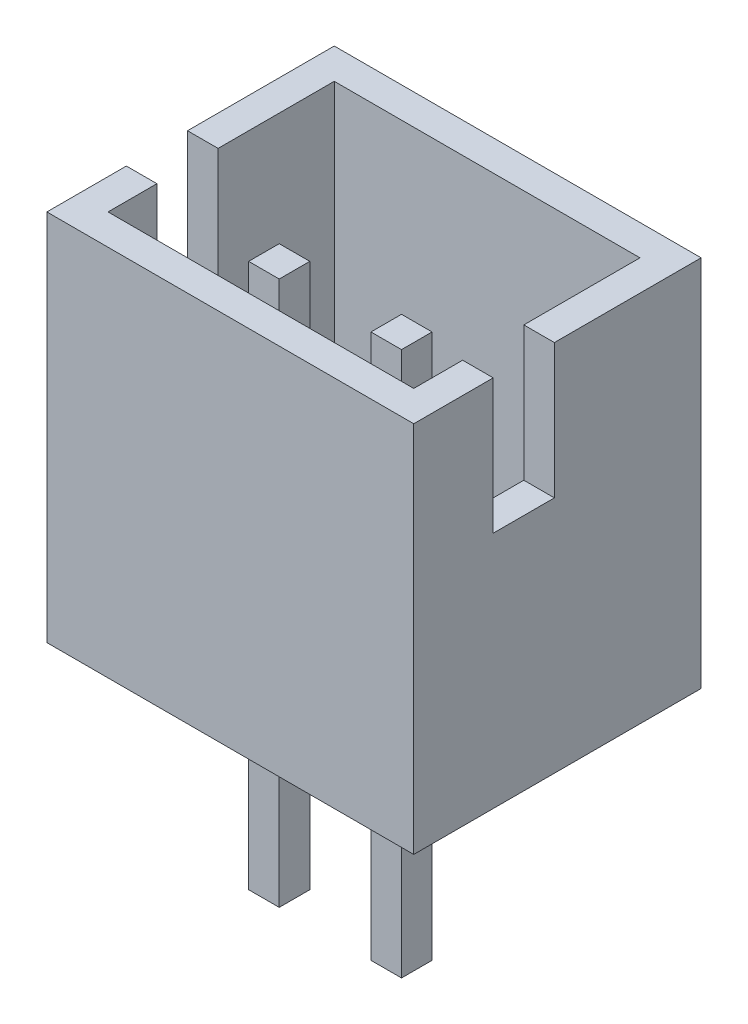
from build123d import *

# Parameters (mm, degrees)
SKETCH1_W                  = 6
SKETCH1_H                  = 4.7
BOSS_EXTRUDE1_DEPTH        = 6.1
SHELL1_T                   = -0.5
SKETCH2_W                  = 0.5
SKETCH2_H                  = 0.5
BOSS_EXTRUDE2_DEPTH        = 5
BOSS_EXTRUDE2_DEPTH_BACK   = 3.9
BOSS_EXTRUDE2_2_DEPTH      = 5
BOSS_EXTRUDE2_2_DEPTH_BACK = 3.9
SKETCH3_W                  = 1
SKETCH3_H                  = 2.2
CUT_EXTRUDE1_DEPTH         = 5.5


with BuildPart() as part:
    # Sketch1 → Boss-Extrude1 (new body)
    with BuildSketch(Plane(origin=(0, 0, 0), x_dir=(1, 0, 0), z_dir=(0, 1, 0))):
        Rectangle(SKETCH1_W, SKETCH1_H)
    extrude(amount=BOSS_EXTRUDE1_DEPTH)

    # Shell1
    shell1_openings = [part.faces().sort_by_distance(p)[0] for p in [
        (0, 6.1, 0),
    ]]
    offset(amount=SHELL1_T, openings=shell1_openings, kind=Kind.INTERSECTION)

    # Sketch3 → Cut-Extrude1 (cut)
    with BuildSketch(Plane.ZY.offset(3)):
        with Locations((0.55, 5)):
            Rectangle(SKETCH3_W, SKETCH3_H)
    cut_extrude1 = extrude(amount=-CUT_EXTRUDE1_DEPTH, mode=Mode.SUBTRACT)

    # Mirror1: Cut-Extrude1 across plane
    add(cut_extrude1.mirror(Plane(origin=(0, 0, 0), x_dir=(0, 0, 1), z_dir=(1, 0, 0))), mode=Mode.SUBTRACT)


with BuildPart() as body_2:
    # Sketch2 → Boss-Extrude2 (new body, two sides)
    with BuildSketch(Plane(origin=(0, 0.5, 0), x_dir=(1, 0, 0), z_dir=(0, 1, 0))) as boss_extrude2_sk:
        with Locations((-1, -0.55)):
            Rectangle(SKETCH2_W, SKETCH2_H)
    extrude(amount=BOSS_EXTRUDE2_DEPTH)
    extrude(boss_extrude2_sk.sketch, amount=-BOSS_EXTRUDE2_DEPTH_BACK)


with BuildPart() as body_3:
    # Sketch2 → Boss-Extrude2 2 (new body, two sides)
    with BuildSketch(Plane(origin=(0, 0.5, 0), x_dir=(1, 0, 0), z_dir=(0, 1, 0))) as boss_extrude2_2_sk:
        with Locations((1, -0.55)):
            Rectangle(SKETCH2_W, SKETCH2_H)
    extrude(amount=BOSS_EXTRUDE2_2_DEPTH)
    extrude(boss_extrude2_2_sk.sketch, amount=-BOSS_EXTRUDE2_2_DEPTH_BACK)


solid = Compound([part.part, body_2.part, body_3.part])
